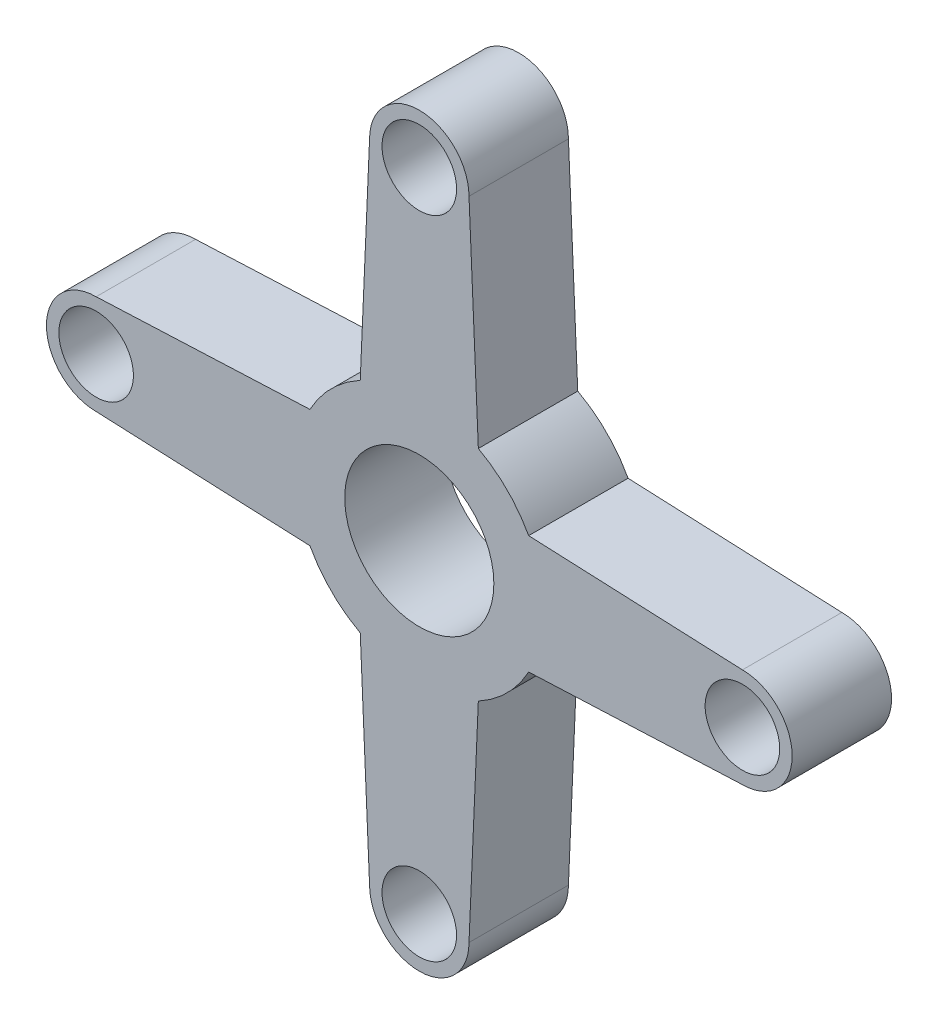
from build123d import *

# Parameters (mm, degrees)
SKETCH1_R           = 3
SKETCH1_R_2         = 1.5
BOSS_EXTRUDE1_DEPTH = 4


with BuildPart() as part:
    # Sketch1 → Boss-Extrude1 (new body)
    with BuildSketch(Plane.XY):
        with BuildLine():
            Line((2, 13), (2.375498971, 4.399659605))
            ThreePointArc((2.375498971, 4.399659605), (3.535533906, 3.535533906), (4.399659605, 2.375498971))
            Line((4.399659605, 2.375498971), (13, 2))
            ThreePointArc((13, 2), (15, 0), (13, -2))
            Line((13, -2), (4.399659605, -2.375498971))
            ThreePointArc((4.399659605, -2.375498971), (3.535533906, -3.535533906), (2.375498971, -4.399659605))
            Line((2.375498971, -4.399659605), (2, -13))
            ThreePointArc((2, -13), (0, -15), (-2, -13))
            Line((-2, -13), (-2.375498971, -4.399659605))
            ThreePointArc((-2.375498971, -4.399659605), (-3.535533906, -3.535533906), (-4.399659605, -2.375498971))
            Line((-4.399659605, -2.375498971), (-13, -2))
            ThreePointArc((-13, -2), (-15, 0), (-13, 2))
            Line((-13, 2), (-4.399659605, 2.375498971))
            ThreePointArc((-4.399659605, 2.375498971), (-3.535533906, 3.535533906), (-2.375498971, 4.399659605))
            Line((-2.375498971, 4.399659605), (-2, 13))
            ThreePointArc((-2, 13), (0, 15), (2, 13))
        make_face()
        Circle(SKETCH1_R, mode=Mode.SUBTRACT)
        with Locations((0, 13)):
            Circle(SKETCH1_R_2, mode=Mode.SUBTRACT)
        with Locations((13, 0)):
            Circle(SKETCH1_R_2, mode=Mode.SUBTRACT)
        with Locations((0, -13)):
            Circle(SKETCH1_R_2, mode=Mode.SUBTRACT)
        with Locations((-13, 0)):
            Circle(SKETCH1_R_2, mode=Mode.SUBTRACT)
    extrude(amount=BOSS_EXTRUDE1_DEPTH)


solid = part.part
